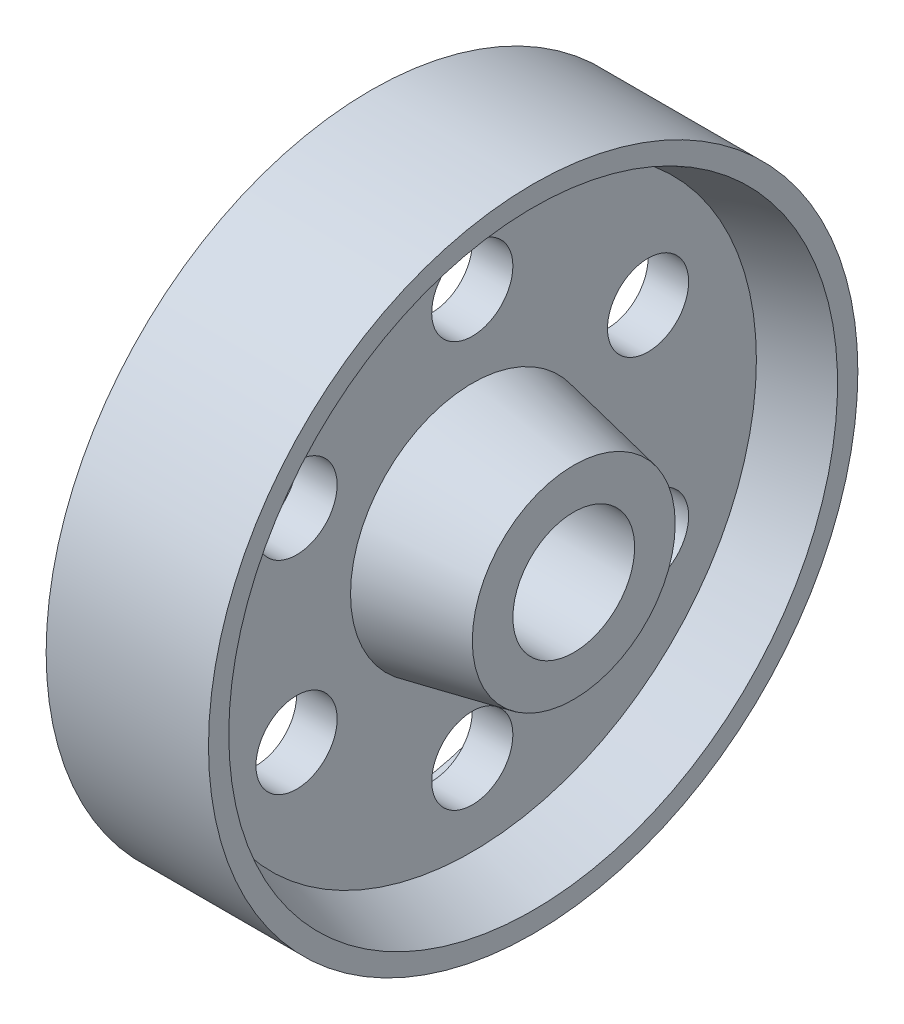
from build123d import *

# Parameters (mm, degrees)
SKETCH2_R          = 0.25
CUT_EXTRUDE2_DEPTH = 1.875
CIRPATTERN2_COUNT  = 6


with BuildPart() as part:
    # Sketch1 → Revolve1 (revolve)
    with BuildSketch(Plane.XY):
        Polygon((0, 0.375), (0.75, 0.375), (0.75, 0.625), (0.125, 0.75), (0.125, 1.75), (0.5, 1.875), (0.5, 2), (0, 2), align=None)
    revolve1 = revolve(axis=Axis((0, 0, 0), (1, 0, 0)))

    # Mirror1: Revolve1 across plane
    add(revolve1.mirror(Plane(origin=(0, 2, 0), x_dir=(0, 0, 1), z_dir=(1, 0, 0))))

    # Sketch2 → Cut-Extrude2 (cut, through all)
    with BuildSketch(Plane(origin=(0.125, 0, 0), x_dir=(0, 0, -1), z_dir=(1, 0, 0))):
        with Locations((1.082531755, 0.625)):
            Circle(SKETCH2_R)
    cut_extrude2 = extrude(amount=-CUT_EXTRUDE2_DEPTH, mode=Mode.SUBTRACT)

    # CirPattern2: Cut-Extrude2 ×6 about axis
    cirpattern2_axis = Axis((0, 0, 0), (1, 0, 0))
    for i in range(1, CIRPATTERN2_COUNT):
        add(cut_extrude2.rotate(cirpattern2_axis, i * 360 / CIRPATTERN2_COUNT), mode=Mode.SUBTRACT)


solid = part.part
